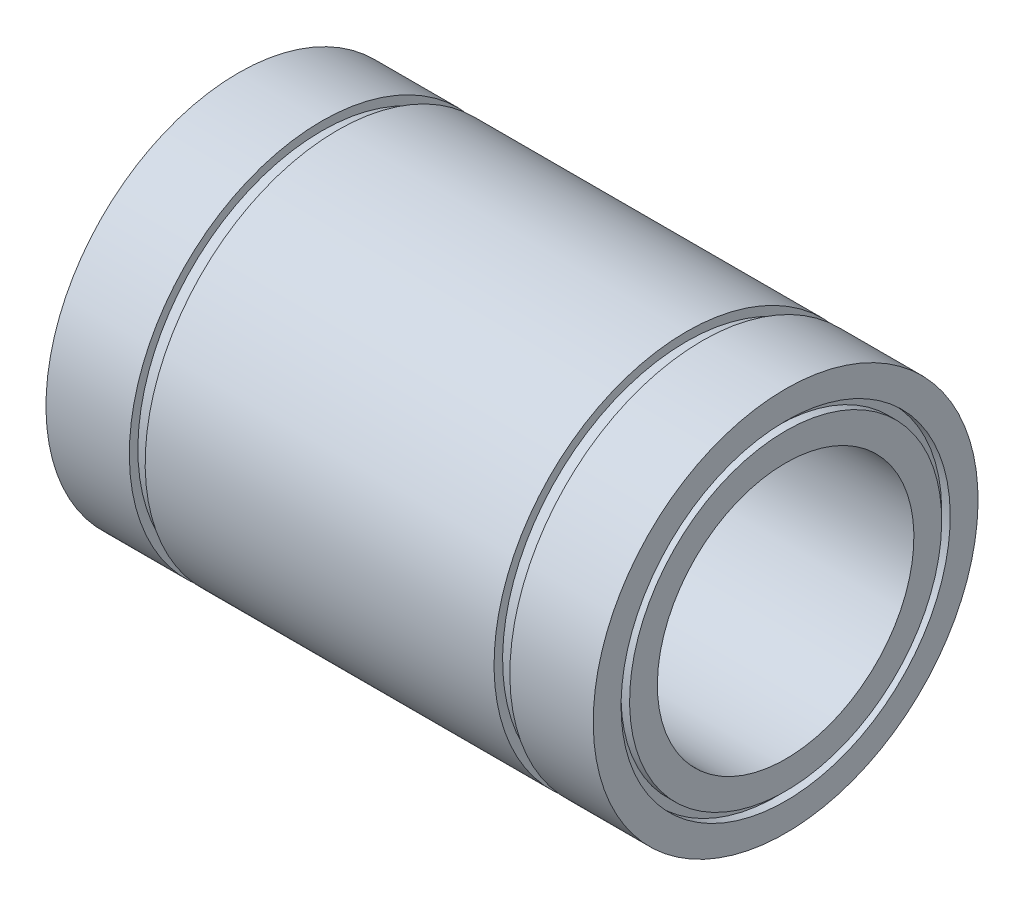
from build123d import *


with BuildPart() as part:
    # Esboço1 → Revolução1 (revolve)
    with BuildSketch(Plane.XY):
        Polygon((-32, 22.5), (-22.25, 22.5), (-22.25, 21.5), (-20.4, 21.5), (-20.4, 22.5), (20.4, 22.5), (20.4, 21.5), (22.25, 21.5), (22.25, 22.5), (32, 22.5), (32, 19.25), (31, 19.25), (31, 18.25), (32, 18.25), (32, 15), (-32, 15), (-32, 18.25), (-31, 18.25), (-31, 19.25), (-32, 19.25), align=None)
    revolve(axis=Axis((0, 0, 0), (-1, 0, 0)))


solid = part.part
